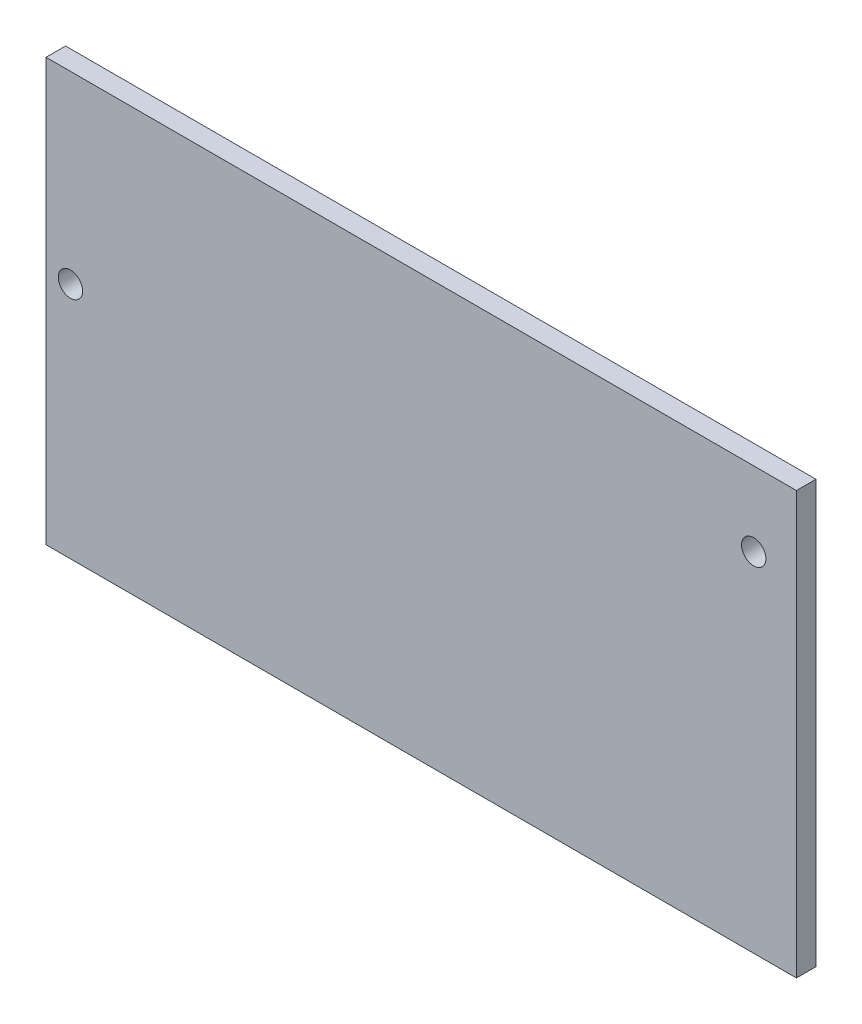
from build123d import *

# Parameters (mm, degrees)
SKETCH1_W           = 61.5
SKETCH1_H           = 34.6
SKETCH1_R           = 1
BOSS_EXTRUDE1_DEPTH = 1.6


with BuildPart() as part:
    # Sketch1 → Boss-Extrude1 (new body)
    with BuildSketch(Plane.XY):
        with Locations((30.75, 17.3)):
            Rectangle(SKETCH1_W, SKETCH1_H)
        with Locations((2, 19.5)):
            Circle(SKETCH1_R, mode=Mode.SUBTRACT)
        with Locations((58, 28.5)):
            Circle(SKETCH1_R, mode=Mode.SUBTRACT)
    extrude(amount=BOSS_EXTRUDE1_DEPTH)


solid = part.part
